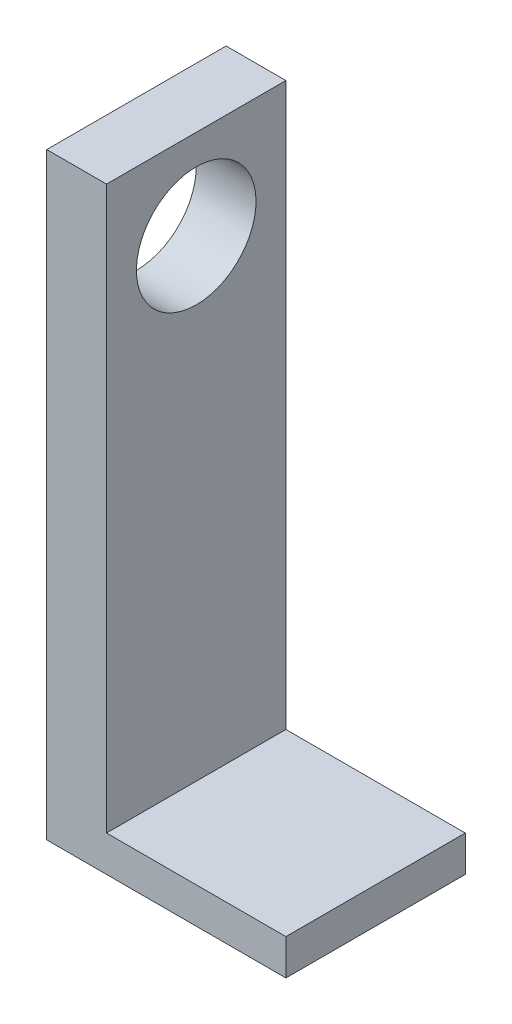
from build123d import *

# Parameters (mm, degrees)
RESSALTO_EXTRUS_O1_DEPTH = 15
ESBO_O2_R                = 5
CORTE_EXTRUS_O1_DEPTH    = 21


with BuildPart() as part:
    # Esboço1 → Ressalto-extrusão1 (new body)
    with BuildSketch(Plane.XY):
        Polygon((0, 0), (20, 0), (20, 3), (5, 3), (5, 50), (0, 50), align=None)
    extrude(amount=RESSALTO_EXTRUS_O1_DEPTH)

    # Esboço2 → Corte-extrusão1 (cut, through all)
    with BuildSketch(Plane.ZY):
        with Locations((7.5, 42.5)):
            Circle(ESBO_O2_R)
    extrude(amount=-CORTE_EXTRUS_O1_DEPTH, mode=Mode.SUBTRACT)


solid = part.part
